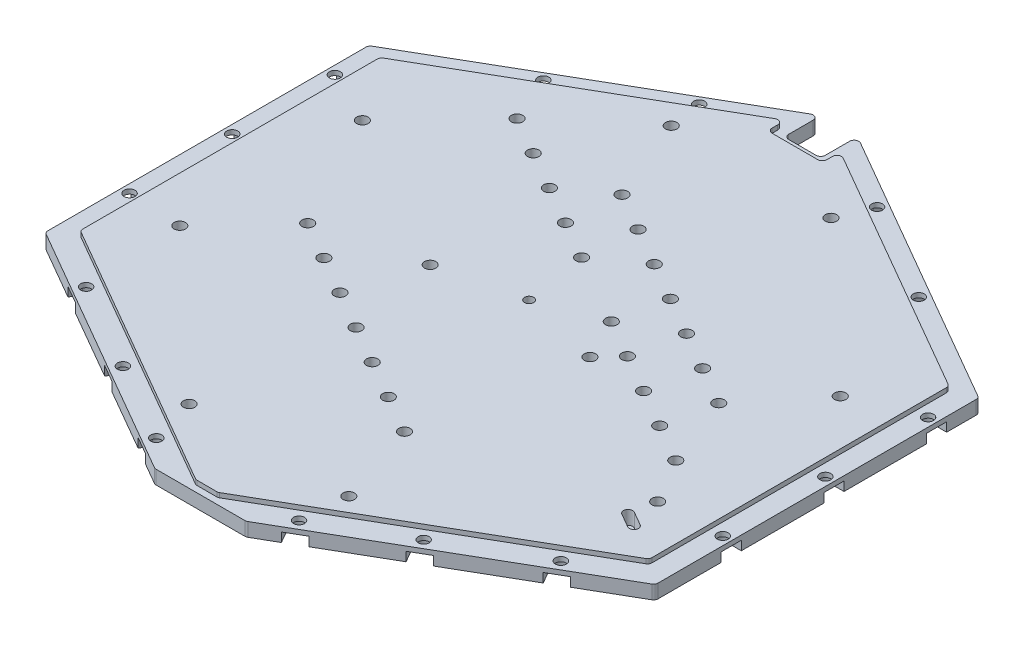
from build123d import *

# Parameters (mm, degrees)
BOSS_EXTRUDE1_DEPTH            = 4
CUT_EXTRUDE1_REACH             = 6
CUT_EXTRUDE3_DEPTH             = 1
CUT_EXTRUDE4_DEPTH             = 3
SKETCH8_R                      = 1
CUT_EXTRUDE5_DEPTH             = 3
CUT_EXTRUDE7_DEPTH             = 5
TAP_DRILL_FOR_M3X0_5_TAP1_D    = 2.5
TAP_DRILL_FOR_M3X0_5_TAP2_D    = 2.5
CHAMFER1_SIZE                  = 2.8
CBORE_FOR_M2_SHCS2_D           = 2.4
CBORE_FOR_M2_SHCS2_CBORE_D     = 4.4
CBORE_FOR_M2_SHCS2_CBORE_DEPTH = 2
SKETCH15_W                     = 12
SKETCH15_H                     = 14.8
CUT_EXTRUDE6_DEPTH             = 1
FILLET1_R                      = 1
CUT_EXTRUDE8_DEPTH             = 2


with BuildPart() as part:
    # Sketch1 → Boss-Extrude1 (new body)
    with BuildSketch(Plane(origin=(0, 0, 0), x_dir=(1, 0, 0), z_dir=(0, 1, 0))):
        Polygon((-67.353829072, -38.886751346), (0, -77.773502692), (67.353829072, -38.886751346), (67.353829072, 38.886751346), (0, 77.773502692), (-67.353829072, 38.886751346), align=None)
    extrude(amount=BOSS_EXTRUDE1_DEPTH)

    # Sketch2 → Cut-Extrude1 (cut, up to next)
    with BuildSketch(Plane(origin=(0, 4, 0), x_dir=(1, 0, 0), z_dir=(0, 1, 0)), mode=Mode.PRIVATE) as cut_extrude1_sk1:
        Polygon((-67.353829072, 38.886751346), (-67.353829072, 31.958548116), (0, 70.845299462), (67.353829072, 31.958548116), (67.353829072, 38.886751346), (0, 77.773502692), align=None)
    cut_extrude1_tool1 = extrude(cut_extrude1_sk1.sketch, amount=-CUT_EXTRUDE1_REACH, mode=Mode.PRIVATE) & part.part
    add(cut_extrude1_tool1.solids().sort_by_distance((-65.930974, 4, -35.42265))[0], mode=Mode.SUBTRACT)

    # Sketch4 → Cut-Extrude3 (cut)
    with BuildSketch(Plane(origin=(0, 4, 0), x_dir=(1, 0, 0), z_dir=(0, 1, 0))):
        Polygon((-67.353829072, 31.958548116), (-67.353829072, -38.886751346), (0, -77.773502692), (67.353829072, -38.886751346), (67.353829072, 31.958548116), (0, 70.845299462), align=None)
        Polygon((62.353829072, 29.649147039), (62.353829072, -36), (0, -72), (-62.353829072, -36), (-62.353829072, 29.649147039), (0, 65.649147039), align=None, mode=Mode.SUBTRACT)
    extrude(amount=-CUT_EXTRUDE3_DEPTH, mode=Mode.SUBTRACT)

    # Sketch5 → Cut-Extrude4 (cut)
    with BuildSketch(Plane.XZ):
        Polygon((0, 77.773502692), (10, 72), (-10, 72), align=None)
        Polygon((-4, -68.535898385), (-4, -59.885898385), (4, -59.885898385), (4, -68.535898385), (0, -70.845299462), align=None)
    extrude(amount=-CUT_EXTRUDE4_DEPTH, mode=Mode.SUBTRACT)

    # Sketch8 → Cut-Extrude5 (cut)
    with BuildSketch(Plane(origin=(0, 4, 0), x_dir=(1, 0, 0), z_dir=(0, 1, 0))):
        Circle(SKETCH8_R)
        with BuildLine():
            Line((53.843094087, -32.241025404), (50.812005174, -30.491025404))
            ThreePointArc((50.812005174, -30.491025404), (50.44597977, -29.125), (51.812005174, -28.758974596))
            Line((51.812005174, -28.758974596), (54.843094087, -30.508974596))
            ThreePointArc((54.843094087, -30.508974596), (55.209119491, -31.875), (53.843094087, -32.241025404))
        make_face()
    extrude(amount=-CUT_EXTRUDE5_DEPTH, mode=Mode.SUBTRACT)

    # Sketch16 → Cut-Extrude7 (cut, through all)
    with BuildSketch(Plane.XZ):
        Polygon((67.353829072, 38.886751346), (66.853829072, 39.175426481), (66.853829072, -31.669872981), (0, -70.267949192), (-66.853829072, -31.669872981), (-66.853829072, 39.175426481), (-67.353829072, 38.886751346), (-67.353829072, -31.958548116), (0, -70.845299462), (67.353829072, -31.958548116), align=None)
    extrude(amount=-CUT_EXTRUDE7_DEPTH, mode=Mode.SUBTRACT)

    # Tap Drill for M3x0.5 Tap1 (through all)
    with Locations(Plane(origin=(0, 4, 0), x_dir=(1, 0, 0), z_dir=(0, 1, 0))):
        with Locations((11.332797781, -38.655018452), (46.533560093, -14.397509662), (40.353561401, 1.195565652), (2.973920584, -33.829018452), (-5.384956614, -29.003018452), (-13.743833811, -24.177018452), (-22.102711008, -19.351018452), (-30.461588206, -14.525018452), (-38.820465403, -9.699018452), (38.174682895, -9.571509662), (29.815805698, -4.745509662), (21.456928501, 0.080490338), (13.098051303, 4.906490338), (-2.299880376, 13.796490338), (-10.658757573, 18.622490338), (-19.017634771, 23.448490338), (-27.376511968, 28.274490338), (-35.735389165, 33.100490338), (31.994684204, 6.021565652), (23.635807007, 10.847565652), (15.276929809, 15.673565652), (6.918052612, 20.499565652), (-1.440824585, 25.325565652), (-9.799701783, 30.151565652)):
            Hole(TAP_DRILL_FOR_M3X0_5_TAP1_D / 2)

    # Tap Drill for M3x0.5 Tap2 (through all)
    with Locations(Plane(origin=(0, 0, 0), x_dir=(-1, 0, 0), z_dir=(0, -1, 0))):
        with Locations((-17.5, 48.637), (17.5, 48.637), (-52.353829072, 15.8185), (-52.353829072, -24.1815), (-17.5, -57), (17.5, -57), (52.353829072, 15.8185), (52.353829072, -24.1815), (17.5, -4.1815), (-17.5, -4.1815)):
            Hole(TAP_DRILL_FOR_M3X0_5_TAP2_D / 2)

    # Chamfer1
    chamfer1_edges = [part.edges().sort_by_distance(p)[0] for p in [
        (0, 3.5, 72),
    ]]
    chamfer(chamfer1_edges, length=CHAMFER1_SIZE)

    # CBORE for M2 SHCS2 (through all)
    with Locations(Plane(origin=(0, 0, 79.328), x_dir=(-1, 0, 0), z_dir=(0, -1, 0))):
        with Locations((-65, 101.748729811), (-41.13620668, 123.578548116), (-19.485571585, 136.078548116), (19.485571585, 136.078548116), (41.13620668, 123.578548116), (65, 101.768729811), (65, 79.268729811), (65, 56.768729811), (52.009618943, 34.268729811), (32.95706006, 23.268729811), (15.636551984, 13.268729811), (-15.636551984, 13.268729811), (-32.95706006, 23.268729811), (-52.009618943, 34.268729811), (-65, 56.748729811), (-65, 79.248729811)):
            CounterBoreHole(CBORE_FOR_M2_SHCS2_D / 2, CBORE_FOR_M2_SHCS2_CBORE_D / 2, CBORE_FOR_M2_SHCS2_CBORE_DEPTH)

    # Sketch15 → Cut-Extrude6 (cut)
    with BuildSketch(Plane(origin=(0, 4, 0), x_dir=(1, 0, 0), z_dir=(0, 1, 0))):
        with Locations((0, 65.649147039)):
            Rectangle(SKETCH15_W, SKETCH15_H)
    extrude(amount=-CUT_EXTRUDE6_DEPTH, mode=Mode.SUBTRACT)

    # Fillet1
    fillet1_edges = [part.edges().sort_by_distance(p)[0] for p in [
        (4, 1.5, -67.958548116),
        (-4, 1.5, -67.958548116),
        (-66.853829072, 1.5, 39.175426481),
        (66.853829072, 1.5, -31.669872981),
        (66.853829072, 1.5, 39.175426481),
        (-66.853829072, 1.5, -31.669872981),
        (-2.424871131, 3.5, 70.6),
        (2.424871131, 3.5, 70.6),
        (62.353829072, 3.5, -29.649147039),
        (62.353829072, 3.5, 36),
        (-62.353829072, 3.5, 36),
        (-62.353829072, 3.5, -29.649147039),
        (6, 3.5, -62.185045424),
        (-6, 3.5, -62.185045424),
        (6, 3.5, -58.249147039),
        (-6, 3.5, -58.249147039),
        (-10, 1.5, 72),
        (10, 1.5, 72),
        (-4, 1.5, -59.885898385),
        (4, 1.5, -59.885898385),
    ]]
    fillet(fillet1_edges, radius=FILLET1_R)

    # Sketch17 → Cut-Extrude8 (cut)
    with BuildSketch(Plane.XZ):
        with BuildLine():
            Line((-65, 24.759270189), (-66.853829072, 24.759270189))
            Line((-66.853829072, 24.759270189), (-66.853829072, 20.359270189))
            Line((-66.853829072, 20.359270189), (-65, 20.359270189))
            ThreePointArc((-65, 20.359270189), (-62.8, 22.559270189), (-65, 24.759270189))
        make_face()
        with BuildLine():
            Line((21.390827473, -55.650548116), (22.37264094, -57.351098923))
            Line((22.37264094, -57.351098923), (18.562129163, -59.551098923))
            Line((18.562129163, -59.551098923), (17.580315697, -57.850548116))
            ThreePointArc((17.580315697, -57.850548116), (18.385571585, -54.845292227), (21.390827473, -55.650548116))
        make_face()
        with BuildLine():
            Line((-65, 2.259270189), (-66.853829072, 2.259270189))
            Line((-66.853829072, 2.259270189), (-66.853829072, -2.140729811))
            Line((-66.853829072, -2.140729811), (-65, -2.140729811))
            ThreePointArc((-65, -2.140729811), (-62.8, 0.059270189), (-65, 2.259270189))
        make_face()
        with BuildLine():
            Line((-65, -20.240729811), (-66.853829072, -20.240729811))
            Line((-66.853829072, -20.240729811), (-66.853829072, -24.640729811))
            Line((-66.853829072, -24.640729811), (-65, -24.640729811))
            ThreePointArc((-65, -24.640729811), (-62.8, -22.440729811), (-65, -20.240729811))
        make_face()
        with BuildLine():
            Line((66.853829072, -24.640729811), (66.853829072, -20.240729811))
            Line((66.853829072, -20.240729811), (65, -20.240729811))
            ThreePointArc((65, -20.240729811), (62.8, -22.440729811), (65, -24.640729811))
            Line((65, -24.640729811), (66.853829072, -24.640729811))
        make_face()
        with BuildLine():
            Line((66.853829072, -2.140729811), (66.853829072, 2.259270189))
            Line((66.853829072, 2.259270189), (65, 2.259270189))
            ThreePointArc((65, 2.259270189), (62.8, 0.059270189), (65, -2.140729811))
            Line((65, -2.140729811), (66.853829072, -2.140729811))
        make_face()
        with BuildLine():
            Line((66.853829072, 20.359270189), (66.853829072, 24.759270189))
            Line((66.853829072, 24.759270189), (65, 24.759270189))
            ThreePointArc((65, 24.759270189), (62.8, 22.559270189), (65, 20.359270189))
            Line((65, 20.359270189), (66.853829072, 20.359270189))
        make_face()
        with BuildLine():
            Line((43.041462568, -43.150548116), (44.023276035, -44.851098923))
            Line((44.023276035, -44.851098923), (40.212764258, -47.051098923))
            Line((40.212764258, -47.051098923), (39.230950791, -45.350548116))
            ThreePointArc((39.230950791, -45.350548116), (40.03620668, -42.345292227), (43.041462568, -43.150548116))
        make_face()
        with BuildLine():
            Line((53.914874832, 43.959270189), (55.078148302, 45.974118943))
            Line((55.078148302, 45.974118943), (51.267636525, 48.174118943))
            Line((51.267636525, 48.174118943), (50.104363055, 46.159270189))
            ThreePointArc((50.104363055, 46.159270189), (50.909618943, 43.154014301), (53.914874832, 43.959270189))
        make_face()
        with BuildLine():
            Line((34.862315948, 54.959270189), (36.025589419, 56.974118943))
            Line((36.025589419, 56.974118943), (32.215077642, 59.174118943))
            Line((32.215077642, 59.174118943), (31.051804172, 57.159270189))
            ThreePointArc((31.051804172, 57.159270189), (31.85706006, 54.154014301), (34.862315948, 54.959270189))
        make_face()
        with BuildLine():
            Line((17.541807873, 64.959270189), (18.705081343, 66.974118943))
            Line((18.705081343, 66.974118943), (14.894569566, 69.174118943))
            Line((14.894569566, 69.174118943), (13.731296096, 67.159270189))
            ThreePointArc((13.731296096, 67.159270189), (14.536551984, 64.154014301), (17.541807873, 64.959270189))
        make_face()
        with BuildLine():
            Line((-14.894569566, 69.174118943), (-13.731296096, 67.159270189))
            ThreePointArc((-13.731296096, 67.159270189), (-14.536551984, 64.154014301), (-17.541807873, 64.959270189))
            Line((-17.541807873, 64.959270189), (-18.705081343, 66.974118943))
            Line((-18.705081343, 66.974118943), (-14.894569566, 69.174118943))
        make_face()
        with BuildLine():
            Line((-32.215077642, 59.174118943), (-31.051804172, 57.159270189))
            ThreePointArc((-31.051804172, 57.159270189), (-31.85706006, 54.154014301), (-34.862315948, 54.959270189))
            Line((-34.862315948, 54.959270189), (-36.025589419, 56.974118943))
            Line((-36.025589419, 56.974118943), (-32.215077642, 59.174118943))
        make_face()
        with BuildLine():
            Line((-51.267636525, 48.174118943), (-50.104363055, 46.159270189))
            ThreePointArc((-50.104363055, 46.159270189), (-50.909618943, 43.154014301), (-53.914874832, 43.959270189))
            Line((-53.914874832, 43.959270189), (-55.078148302, 45.974118943))
            Line((-55.078148302, 45.974118943), (-51.267636525, 48.174118943))
        make_face()
        with BuildLine():
            Line((-40.212764258, -47.051098923), (-39.230950791, -45.350548116))
            ThreePointArc((-39.230950791, -45.350548116), (-40.03620668, -42.345292227), (-43.041462568, -43.150548116))
            Line((-43.041462568, -43.150548116), (-44.023276035, -44.851098923))
            Line((-44.023276035, -44.851098923), (-40.212764258, -47.051098923))
        make_face()
        with BuildLine():
            Line((-18.562129163, -59.551098923), (-17.580315697, -57.850548116))
            ThreePointArc((-17.580315697, -57.850548116), (-18.385571585, -54.845292227), (-21.390827473, -55.650548116))
            Line((-21.390827473, -55.650548116), (-22.37264094, -57.351098923))
            Line((-22.37264094, -57.351098923), (-18.562129163, -59.551098923))
        make_face()
    extrude(amount=-CUT_EXTRUDE8_DEPTH, mode=Mode.SUBTRACT)


solid = part.part
